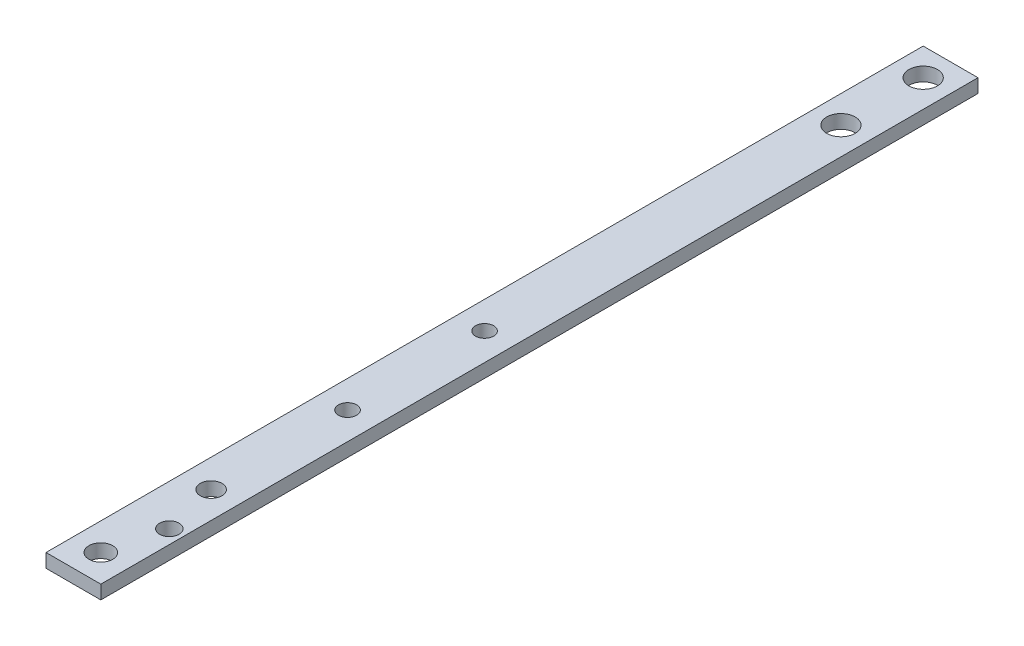
from build123d import *

# Parameters (mm, degrees)
SKETCH1_W             = 12.7
SKETCH1_H             = 3.175
BOSS_EXTRUDE1_DEPTH   = 203.2
M6_CLEARANCE_HOLE1_D  = 6.6
M5X0_8_TAPPED_HOLE1_D = 4.2
M6X1_0_TAPPED_HOLE1_D = 5
M5_CLEARANCE_HOLE1_D  = 5.5
M4_CLEARANCE_HOLE1_D  = 4.5


with BuildPart() as part:
    # Sketch1 → Boss-Extrude1 (new body)
    with BuildSketch(Plane.XY):
        with Locations((6.35, 1.5875)):
            Rectangle(SKETCH1_W, SKETCH1_H)
    extrude(amount=BOSS_EXTRUDE1_DEPTH)

    # M6 Clearance Hole1 (through all)
    with Locations(Plane(origin=(0, 0, 0), x_dir=(-1, 0, 0), z_dir=(0, -1, 0))):
        with Locations((-6.35, -6.35), (-6.35, -25.4)):
            Hole(M6_CLEARANCE_HOLE1_D / 2)

    # M5x0.8 Tapped Hole1 (through all)
    with Locations(Plane(origin=(0, 0, 0), x_dir=(-1, 0, 0), z_dir=(0, -1, 0))):
        with Locations((-6.35, -139.7), (-6.35, -107.95)):
            Hole(M5X0_8_TAPPED_HOLE1_D / 2)

    # M6x1.0 Tapped Hole1 (through all)
    with Locations(Plane(origin=(0, 3.175, 0), x_dir=(1, 0, 0), z_dir=(0, 1, 0))):
        with Locations((6.506704553, -171.45)):
            Hole(M6X1_0_TAPPED_HOLE1_D / 2)

    # M5 Clearance Hole1 (through all)
    with Locations(Plane(origin=(0, 3.175, 0), x_dir=(1, 0, 0), z_dir=(0, 1, 0))):
        with Locations((6.35, -196.85)):
            Hole(M5_CLEARANCE_HOLE1_D / 2)

    # M4 Clearance Hole1 (through all)
    with Locations(Plane(origin=(0, 0, 0), x_dir=(-1, 0, 0), z_dir=(0, -1, 0))):
        with Locations((-9.525, -184.15)):
            Hole(M4_CLEARANCE_HOLE1_D / 2)


solid = part.part
